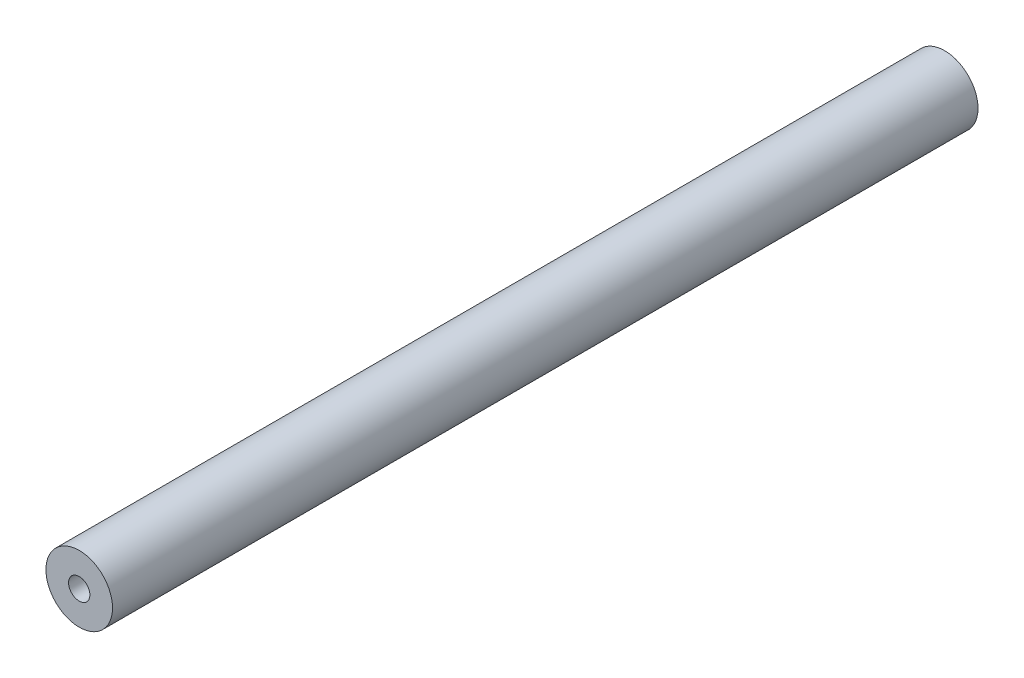
from build123d import *

# Parameters (mm, degrees)
SKETCH1_R           = 6.35
SKETCH1_R_2         = 2.032
BOSS_EXTRUDE1_DEPTH = 165.1


with BuildPart() as part:
    # Sketch1 → Boss-Extrude1 (new body)
    with BuildSketch(Plane.XY):
        Circle(SKETCH1_R)
        Circle(SKETCH1_R_2, mode=Mode.SUBTRACT)
    extrude(amount=BOSS_EXTRUDE1_DEPTH)


solid = part.part
